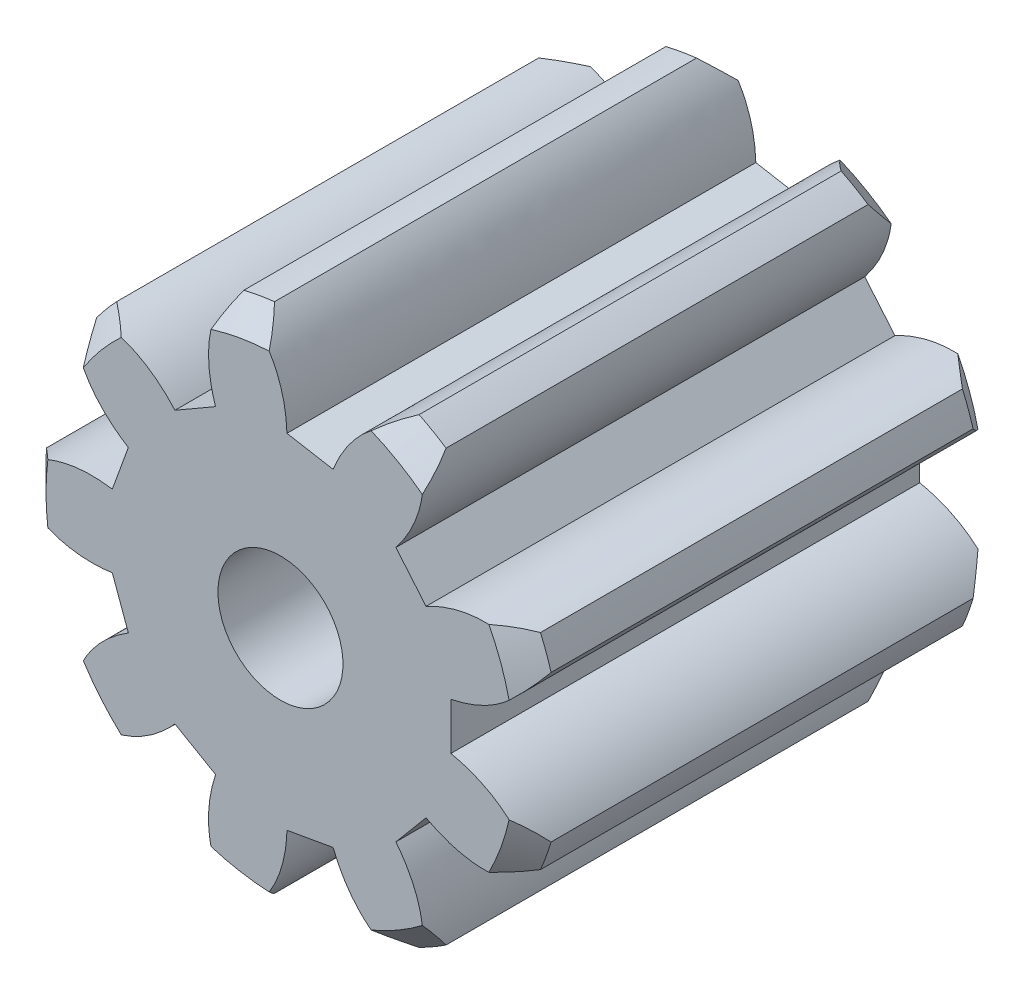
from build123d import *

# Parameters (mm, degrees)
SKETCH_1_R               = 3.3
EXTRUDE_1_DEPTH          = 6
CHAMFER_1_SIZE           = 0.3
CUT_EXTRUDE_1_DEPTH      = 8.601315676
PATTERN_CIRCULAR_1_COUNT = 9
SKETCH_3_R               = 0.8
CUT_EXTRUDE_2_DEPTH      = 8.592018845


with BuildPart() as part:
    # 草图1 → 凸台-拉伸1 (new body)
    with BuildSketch(Plane.XY):
        Circle(SKETCH_1_R)
    extrude(amount=EXTRUDE_1_DEPTH)

    # 倒角1
    chamfer_1_edges = [part.edges().sort_by_distance(p)[0] for p in [
        (-3.3, 0, 6),
        (-3.3, 0, 0),
    ]]
    chamfer(chamfer_1_edges, length=CHAMFER_1_SIZE)

    # 草图2 → 切除-拉伸1 (cut, through all)
    with BuildSketch(Plane(origin=(0, 0, 0), x_dir=(-1, 0, 0), z_dir=(0, 0, -1))):
        with BuildLine():
            Line((-2.18033666, 0.3), (-2.18033666, -0.3))
            add(Edge.make_bspline(
                [(-2.18033666, -0.3), (-3.086972582, -0.488594071), (-3.38033666, -1.4)],
                knots=[0, 0, 0, 1, 1, 1], degree=2))
            Line((-3.38033666, -1.4), (-3.38033666, 1.4))
            add(Edge.make_bspline(
                [(-2.18033666, 0.3), (-3.086972582, 0.488594071), (-3.38033666, 1.4)],
                knots=[0, 0, 0, 1, 1, 1], degree=2))
        make_face()
    cut_extrude_1 = extrude(amount=-CUT_EXTRUDE_1_DEPTH, mode=Mode.SUBTRACT)

    # 阵列(圆周)1: 切除-拉伸1 ×9 about axis
    pattern_circular_1_axis = Axis((0, 0, 0), (0, 0, -1))
    for i in range(1, PATTERN_CIRCULAR_1_COUNT):
        add(cut_extrude_1.rotate(pattern_circular_1_axis, i * 360 / PATTERN_CIRCULAR_1_COUNT), mode=Mode.SUBTRACT)

    # 草图3 → 切除-拉伸2 (cut, through all)
    with BuildSketch(Plane(origin=(0, 0, 0), x_dir=(-1, 0, 0), z_dir=(0, 0, -1))):
        Circle(SKETCH_3_R)
    extrude(amount=-CUT_EXTRUDE_2_DEPTH, mode=Mode.SUBTRACT)


solid = part.part
